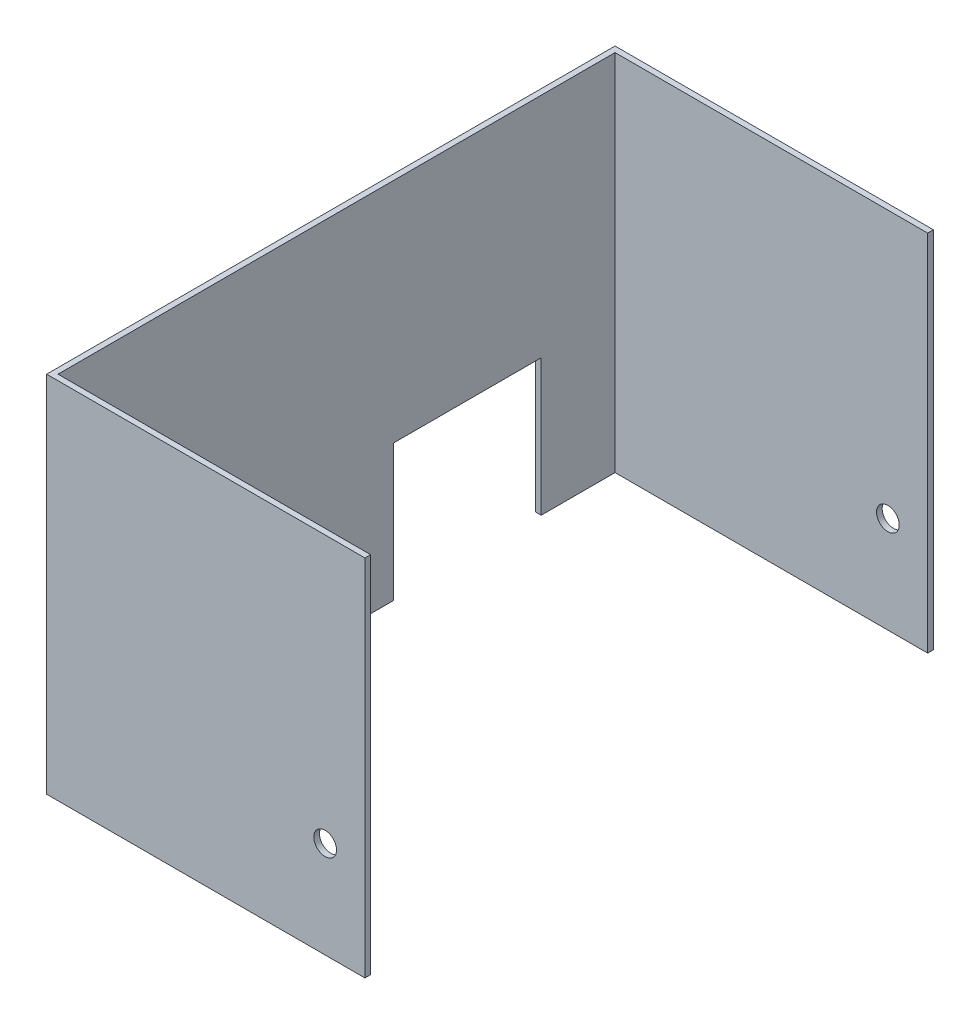
from build123d import *

# Parameters (mm, degrees)
SKETCH1_W           = 355.6
SKETCH1_H           = 635
BOSS_EXTRUDE1_DEPTH = 406.4
SHELL1_T            = -6.35
SKETCH2_W           = 165.1
SKETCH2_H           = 152.4
CUT_EXTRUDE1_DEPTH  = 7.35
SKETCH3_R           = 12.7
CUT_EXTRUDE2_DEPTH  = 636


with BuildPart() as part:
    # Sketch1 → Boss-Extrude1 (new body)
    with BuildSketch(Plane(origin=(0, 0, 0), x_dir=(1, 0, 0), z_dir=(0, 1, 0))):
        with Locations((177.8, 317.5)):
            Rectangle(SKETCH1_W, SKETCH1_H)
    extrude(amount=BOSS_EXTRUDE1_DEPTH)

    # Shell1
    shell1_openings = [part.faces().sort_by_distance(p)[0] for p in [
        (177.8, 406.4, -317.5),
        (177.8, 0, -317.5),
        (355.6, 203.2, -317.5),
    ]]
    offset(amount=SHELL1_T, openings=shell1_openings, kind=Kind.INTERSECTION)

    # Sketch2 → Cut-Extrude1 (cut, through all)
    with BuildSketch(Plane(origin=(6.35, 0, 0), x_dir=(0, 0, -1), z_dir=(1, 0, 0))):
        with Locations((463.55, 76.2)):
            Rectangle(SKETCH2_W, SKETCH2_H)
    extrude(amount=-CUT_EXTRUDE1_DEPTH, mode=Mode.SUBTRACT)

    # Sketch3 → Cut-Extrude2 (cut, through all)
    with BuildSketch(Plane.XY):
        with Locations((311.15, 107.95)):
            Circle(SKETCH3_R)
    extrude(amount=-CUT_EXTRUDE2_DEPTH, mode=Mode.SUBTRACT)


solid = part.part
